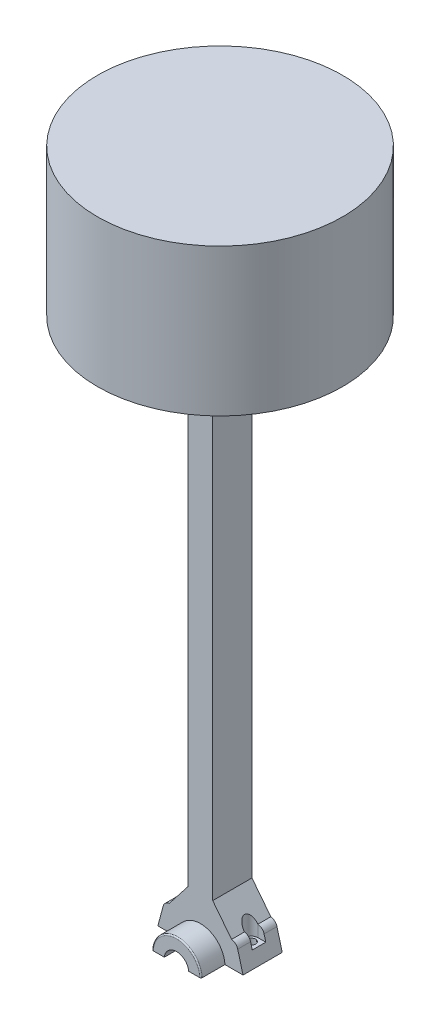
from build123d import *

# Parameters (mm, degrees)
CYLINDRE_DEPTH          = 50
FORME_DEPTH             = 32
CONG_S_R6_R             = 6
LAMAGE_START            = -10.276417
LAMAGE_DEPTH            = 10.276417
ESQUISSE_TROU_R         = 3.5
TROU_DEPTH              = 13
CONG_R10_R              = 10
ESQUISSE_AL_SAGE_R      = 10
AL_SAGE_DEPTH           = 49
ESQUISSE_FRAISAGE_W     = 72
ESQUISSE_FRAISAGE_H     = 3
FRAISAGE_DEPTH          = 52.5000001
BOSS_EXTRU_1_DEPTH      = 32
ENL_V_MAT_EXTRU_1_DEPTH = 20
ENL_V_MAT_EXTRU_2_DEPTH = 20
CONG_1_R                = 1
ESQUISSE8_R             = 100
BOSS_EXTRU_4_DEPTH      = 120


with BuildPart() as part:
    # Esquisse cylindre → Cylindre (new body)
    with BuildSketch(Plane.XY):
        with BuildLine():
            Line((-20, 0), (20, 0))
            ThreePointArc((20, 0), (0, 20), (-20, 0))
        make_face()
    extrude(amount=CYLINDRE_DEPTH)

    # Esquisse forme → Forme (add)
    with BuildSketch(Plane(origin=(0, 0, -1.5), x_dir=(-1, 0, 0), z_dir=(0, 0, -1))):
        Polygon((-35, 0), (35, 0), (29.373066959, 21), (0, 25), (-29.373066959, 21), align=None)
    extrude(amount=-FORME_DEPTH)

    # Congés R6
    cong_s_r6_edges = [part.edges().sort_by_distance(p)[0] for p in [
        (29.373066959, 21, 14.5),
        (-29.373066959, 21, 14.5),
    ]]
    fillet(cong_s_r6_edges, radius=CONG_S_R6_R)

    # Esquisse lamage → Lamage (cut)
    with BuildSketch(Plane.XZ.offset(-12).offset(LAMAGE_START)):
        with BuildLine():
            Line((25.5, 20), (34, 20))
            Line((34, 20), (34, 9))
            Line((34, 9), (25.5, 9))
            ThreePointArc((25.5, 9), (20, 14.5), (25.5, 20))
        make_face()
    lamage = extrude(amount=LAMAGE_DEPTH, mode=Mode.SUBTRACT)

    # Esquisse trou → Trou (cut, through all)
    with BuildSketch(Plane(origin=(0, 12, 0), x_dir=(-1, 0, 0), z_dir=(0, 1, 0))):
        with Locations((-25.5, 14.5)):
            Circle(ESQUISSE_TROU_R)
    trou = extrude(amount=-TROU_DEPTH, mode=Mode.SUBTRACT)

    # Symétrie trou: Lamage, Trou across plane
    add(lamage.mirror(Plane(origin=(0, 0, 0), x_dir=(0, 0, 1), z_dir=(1, 0, 0))), mode=Mode.SUBTRACT)
    add(trou.mirror(Plane(origin=(0, 0, 0), x_dir=(0, 0, 1), z_dir=(1, 0, 0))), mode=Mode.SUBTRACT)

    # Congé R10
    cong_r10_edges = [part.edges().sort_by_distance(p)[0] for p in [
        (0, 25, 14.5),
    ]]
    fillet(cong_r10_edges, radius=CONG_R10_R)

    # Esquisse alésage → Alésage (cut)
    with BuildSketch(Plane.XY.offset(50)):
        Circle(ESQUISSE_AL_SAGE_R)
    extrude(amount=-AL_SAGE_DEPTH, mode=Mode.SUBTRACT)

    # Esquisse fraisage → Fraisage (cut, through all)
    with BuildSketch(Plane.XY.offset(50)):
        with Locations((0, -0.5)):
            Rectangle(ESQUISSE_FRAISAGE_W, ESQUISSE_FRAISAGE_H)
    extrude(amount=-FRAISAGE_DEPTH, mode=Mode.SUBTRACT)

    # Esquisse2 → Boss.-Extru.1 (add)
    with BuildSketch(Plane(origin=(0, 0, -1.5), x_dir=(-1, 0, 0), z_dir=(0, 0, -1))):
        with BuildLine():
            Line((-25.419751719, 21.538359204), (-10.028214835, 41.238628045))
            Line((-10.028214835, 41.238628045), (-10.028214835, 441.238628045))
            Line((-10.028214835, 441.238628045), (10.028214835, 441.238628045))
            Line((10.028214835, 441.238628045), (10.028214835, 41.238628045))
            Line((10.028214835, 41.238628045), (25.419751719, 21.538359204))
            Line((25.419751719, 21.538359204), (1.349337639, 24.816248315))
            ThreePointArc((1.349337639, 24.816248315), (0, 24.907702108), (-1.349337639, 24.816248315))
            Line((-1.349337639, 24.816248315), (-25.419751719, 21.538359204))
        make_face()
    extrude(amount=-BOSS_EXTRU_1_DEPTH)

    # Esquisse3 → Enlèv. mat.-Extru.1 (cut)
    with BuildSketch(Plane(origin=(0, 12, 0), x_dir=(1, 0, 0), z_dir=(0, 1, 0))):
        with BuildLine():
            Line((31.784609691, -9), (25.5, -9))
            ThreePointArc((25.5, -9), (20, -14.5), (25.5, -20))
            Line((25.5, -20), (31.784609691, -20))
            Line((31.784609691, -20), (31.784609691, -9))
        make_face()
    extrude(amount=ENL_V_MAT_EXTRU_1_DEPTH, mode=Mode.SUBTRACT)

    # Esquisse4 → Enlèv. mat.-Extru.2 (cut)
    with BuildSketch(Plane(origin=(0, 12, 0), x_dir=(1, 0, 0), z_dir=(0, 1, 0))):
        with BuildLine():
            Line((-31.784609691, -20), (-25.5, -20))
            ThreePointArc((-25.5, -20), (-20, -14.5), (-25.5, -9))
            Line((-25.5, -9), (-31.784609691, -9))
            Line((-31.784609691, -9), (-31.784609691, -20))
        make_face()
    extrude(amount=ENL_V_MAT_EXTRU_2_DEPTH, mode=Mode.SUBTRACT)

    # Congé1
    cong_1_edges = [part.edges().sort_by_distance(p)[0] for p in [
        (0, 20, 50),
    ]]
    fillet(cong_1_edges, radius=CONG_1_R)

    # Esquisse8 → Boss.-Extru.4 (add)
    with BuildSketch(Plane(origin=(0, 441.238628045, 0), x_dir=(1, 0, 0), z_dir=(0, 1, 0))):
        with Locations((0, -14.5)):
            Circle(ESQUISSE8_R)
    extrude(amount=BOSS_EXTRU_4_DEPTH)


solid = part.part
